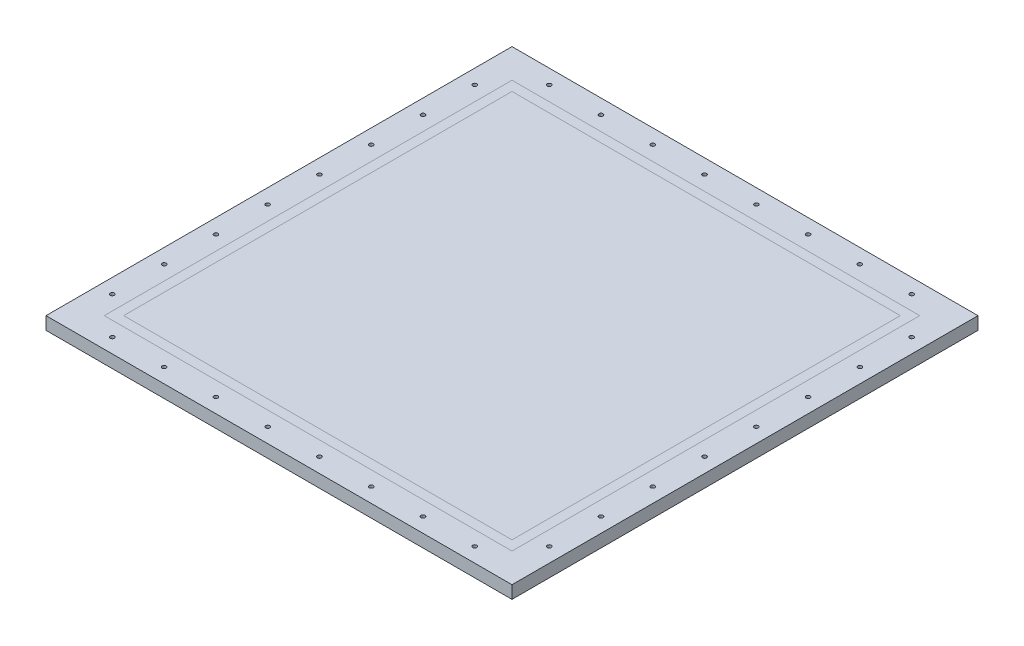
from build123d import *

# Parameters (mm, degrees)
SKETCH1_W                    = 800.1
SKETCH1_H                    = 800.1
BOSS_EXTRUDE1_DEPTH          = 25
SKETCH2_W                    = 914.4
SKETCH2_H                    = 914.4
SKETCH2_W_2                  = 800.1
SKETCH2_H_2                  = 800.1
BOSS_EXTRUDE2_DEPTH          = 25
SKETCH3_W                    = 3.96875
SKETCH3_H                    = 25
LPATTERN1_COUNT              = 4
LPATTERN1_PITCH              = 101.6
LPATTERN1_COL_COUNT          = 5
LPATTERN1_COL_PITCH          = 101.6
CIRPATTERN1_COUNT            = 4
CIRPATTERN1_COPY_1_SKETCH_W  = 3.96875
CIRPATTERN1_COPY_1_SKETCH_H  = 25
CIRPATTERN1_COPY_2_SKETCH_W  = 3.96875
CIRPATTERN1_COPY_2_SKETCH_H  = 25
CIRPATTERN1_COPY_3_SKETCH_W  = 3.96875
CIRPATTERN1_COPY_3_SKETCH_H  = 25
CIRPATTERN1_COPY_4_SKETCH_W  = 3.96875
CIRPATTERN1_COPY_4_SKETCH_H  = 25
CIRPATTERN1_COPY_5_SKETCH_W  = 3.96875
CIRPATTERN1_COPY_5_SKETCH_H  = 25
CIRPATTERN1_COPY_6_SKETCH_W  = 3.96875
CIRPATTERN1_COPY_6_SKETCH_H  = 25
CIRPATTERN1_COPY_7_SKETCH_W  = 3.96875
CIRPATTERN1_COPY_7_SKETCH_H  = 25
CIRPATTERN1_COPY_8_SKETCH_W  = 3.96875
CIRPATTERN1_COPY_8_SKETCH_H  = 25
CIRPATTERN1_COPY_9_SKETCH_W  = 3.96875
CIRPATTERN1_COPY_9_SKETCH_H  = 25
CIRPATTERN1_COPY_10_SKETCH_W = 3.96875
CIRPATTERN1_COPY_10_SKETCH_H = 25
CIRPATTERN1_COPY_11_SKETCH_W = 3.96875
CIRPATTERN1_COPY_11_SKETCH_H = 25
CIRPATTERN1_COPY_12_SKETCH_W = 3.96875
CIRPATTERN1_COPY_12_SKETCH_H = 25
CIRPATTERN1_COPY_13_SKETCH_W = 3.96875
CIRPATTERN1_COPY_13_SKETCH_H = 25
CIRPATTERN1_COPY_14_SKETCH_W = 3.96875
CIRPATTERN1_COPY_14_SKETCH_H = 25
CIRPATTERN1_COPY_15_SKETCH_W = 3.96875
CIRPATTERN1_COPY_15_SKETCH_H = 25
CIRPATTERN1_COPY_16_SKETCH_W = 3.96875
CIRPATTERN1_COPY_16_SKETCH_H = 25
CIRPATTERN1_COPY_17_SKETCH_W = 3.96875
CIRPATTERN1_COPY_17_SKETCH_H = 25
CIRPATTERN1_COPY_18_SKETCH_W = 3.96875
CIRPATTERN1_COPY_18_SKETCH_H = 25
CIRPATTERN1_COPY_19_SKETCH_W = 3.96875
CIRPATTERN1_COPY_19_SKETCH_H = 25
CIRPATTERN1_COPY_20_SKETCH_W = 3.96875
CIRPATTERN1_COPY_20_SKETCH_H = 25
CIRPATTERN1_COPY_21_SKETCH_W = 3.96875
CIRPATTERN1_COPY_21_SKETCH_H = 25


with BuildPart() as part:
    # Sketch1 → Boss-Extrude1 (new body)
    with BuildSketch(Plane(origin=(0, 0, 0), x_dir=(1, 0, 0), z_dir=(0, 1, 0))):
        Rectangle(SKETCH1_W, SKETCH1_H)
    extrude(amount=-BOSS_EXTRUDE1_DEPTH)


with BuildPart() as body_2:
    # Sketch2 → Boss-Extrude2 (new body, through all)
    with BuildSketch(Plane(origin=(0, 0, 0), x_dir=(1, 0, 0), z_dir=(0, 1, 0))):
        Rectangle(SKETCH2_W, SKETCH2_H)
        Rectangle(SKETCH2_W_2, SKETCH2_H_2, mode=Mode.SUBTRACT)
    extrude(amount=-BOSS_EXTRUDE2_DEPTH)

    # Sketch3 → 3_8-16 Tapped Hole1 (revolve, cut)
    with BuildSketch(Plane(origin=(-428.625, 0, 50.8), x_dir=(0, 0, 1), z_dir=(1, 0, 0))):
        with Locations((1.984375, 12.5)):
            Rectangle(SKETCH3_W, SKETCH3_H)
    f_3_8_16_tapped_hole1 = revolve(axis=Axis((-428.625, 6.35, 50.8), (0, -1, 0)), mode=Mode.SUBTRACT)

    # LPattern1: 3_8-16 Tapped Hole1 ×4
    with Locations(*[(0, 0, i * LPATTERN1_PITCH) for i in range(1, LPATTERN1_COUNT)]):
        add(f_3_8_16_tapped_hole1, mode=Mode.SUBTRACT)

    # LPattern1 col: 3_8-16 Tapped Hole1 ×5
    with Locations(*[(0, 0, -i * LPATTERN1_COL_PITCH) for i in range(1, LPATTERN1_COL_COUNT)]):
        add(f_3_8_16_tapped_hole1, mode=Mode.SUBTRACT)

    # CirPattern1: 3_8-16 Tapped Hole1 ×4 about axis
    cirpattern1_axis = Axis((0, 0, 0), (0, 1, 0))
    for i in range(1, CIRPATTERN1_COUNT):
        add(f_3_8_16_tapped_hole1.rotate(cirpattern1_axis, i * 360 / CIRPATTERN1_COUNT), mode=Mode.SUBTRACT)

    # CirPattern1 copy 1 sketch → CirPattern1 copy 1 (revolve, cut)
    with BuildSketch(Plane(origin=(152.4, 0, 428.625), x_dir=(1, 0, 0), z_dir=(0, 0, -1))):
        with Locations((1.984375, 12.5)):
            Rectangle(CIRPATTERN1_COPY_1_SKETCH_W, CIRPATTERN1_COPY_1_SKETCH_H)
    revolve(axis=Axis((152.4, 6.35, 428.625), (0, -1, 0)), mode=Mode.SUBTRACT)

    # CirPattern1 copy 2 sketch → CirPattern1 copy 2 (revolve, cut)
    with BuildSketch(Plane(origin=(428.625, 0, -152.4), x_dir=(0, 0, -1), z_dir=(-1, 0, 0))):
        with Locations((1.984375, 12.5)):
            Rectangle(CIRPATTERN1_COPY_2_SKETCH_W, CIRPATTERN1_COPY_2_SKETCH_H)
    revolve(axis=Axis((428.625, 6.35, -152.4), (0, -1, 0)), mode=Mode.SUBTRACT)

    # CirPattern1 copy 3 sketch → CirPattern1 copy 3 (revolve, cut)
    with BuildSketch(Plane(origin=(-152.4, 0, -428.625), x_dir=(-1, 0, 0), z_dir=(0, 0, 1))):
        with Locations((1.984375, 12.5)):
            Rectangle(CIRPATTERN1_COPY_3_SKETCH_W, CIRPATTERN1_COPY_3_SKETCH_H)
    revolve(axis=Axis((-152.4, 6.35, -428.625), (0, -1, 0)), mode=Mode.SUBTRACT)

    # CirPattern1 copy 4 sketch → CirPattern1 copy 4 (revolve, cut)
    with BuildSketch(Plane(origin=(254, 0, 428.625), x_dir=(1, 0, 0), z_dir=(0, 0, -1))):
        with Locations((1.984375, 12.5)):
            Rectangle(CIRPATTERN1_COPY_4_SKETCH_W, CIRPATTERN1_COPY_4_SKETCH_H)
    revolve(axis=Axis((254, 6.35, 428.625), (0, -1, 0)), mode=Mode.SUBTRACT)

    # CirPattern1 copy 5 sketch → CirPattern1 copy 5 (revolve, cut)
    with BuildSketch(Plane(origin=(428.625, 0, -254), x_dir=(0, 0, -1), z_dir=(-1, 0, 0))):
        with Locations((1.984375, 12.5)):
            Rectangle(CIRPATTERN1_COPY_5_SKETCH_W, CIRPATTERN1_COPY_5_SKETCH_H)
    revolve(axis=Axis((428.625, 6.35, -254), (0, -1, 0)), mode=Mode.SUBTRACT)

    # CirPattern1 copy 6 sketch → CirPattern1 copy 6 (revolve, cut)
    with BuildSketch(Plane(origin=(-254, 0, -428.625), x_dir=(-1, 0, 0), z_dir=(0, 0, 1))):
        with Locations((1.984375, 12.5)):
            Rectangle(CIRPATTERN1_COPY_6_SKETCH_W, CIRPATTERN1_COPY_6_SKETCH_H)
    revolve(axis=Axis((-254, 6.35, -428.625), (0, -1, 0)), mode=Mode.SUBTRACT)

    # CirPattern1 copy 7 sketch → CirPattern1 copy 7 (revolve, cut)
    with BuildSketch(Plane(origin=(355.6, 0, 428.625), x_dir=(1, 0, 0), z_dir=(0, 0, -1))):
        with Locations((1.984375, 12.5)):
            Rectangle(CIRPATTERN1_COPY_7_SKETCH_W, CIRPATTERN1_COPY_7_SKETCH_H)
    revolve(axis=Axis((355.6, 6.35, 428.625), (0, -1, 0)), mode=Mode.SUBTRACT)

    # CirPattern1 copy 8 sketch → CirPattern1 copy 8 (revolve, cut)
    with BuildSketch(Plane(origin=(428.625, 0, -355.6), x_dir=(0, 0, -1), z_dir=(-1, 0, 0))):
        with Locations((1.984375, 12.5)):
            Rectangle(CIRPATTERN1_COPY_8_SKETCH_W, CIRPATTERN1_COPY_8_SKETCH_H)
    revolve(axis=Axis((428.625, 6.35, -355.6), (0, -1, 0)), mode=Mode.SUBTRACT)

    # CirPattern1 copy 9 sketch → CirPattern1 copy 9 (revolve, cut)
    with BuildSketch(Plane(origin=(-355.6, 0, -428.625), x_dir=(-1, 0, 0), z_dir=(0, 0, 1))):
        with Locations((1.984375, 12.5)):
            Rectangle(CIRPATTERN1_COPY_9_SKETCH_W, CIRPATTERN1_COPY_9_SKETCH_H)
    revolve(axis=Axis((-355.6, 6.35, -428.625), (0, -1, 0)), mode=Mode.SUBTRACT)

    # CirPattern1 copy 10 sketch → CirPattern1 copy 10 (revolve, cut)
    with BuildSketch(Plane(origin=(-50.8, 0, 428.625), x_dir=(1, 0, 0), z_dir=(0, 0, -1))):
        with Locations((1.984375, 12.5)):
            Rectangle(CIRPATTERN1_COPY_10_SKETCH_W, CIRPATTERN1_COPY_10_SKETCH_H)
    revolve(axis=Axis((-50.8, 6.35, 428.625), (0, -1, 0)), mode=Mode.SUBTRACT)

    # CirPattern1 copy 11 sketch → CirPattern1 copy 11 (revolve, cut)
    with BuildSketch(Plane(origin=(428.625, 0, 50.8), x_dir=(0, 0, -1), z_dir=(-1, 0, 0))):
        with Locations((1.984375, 12.5)):
            Rectangle(CIRPATTERN1_COPY_11_SKETCH_W, CIRPATTERN1_COPY_11_SKETCH_H)
    revolve(axis=Axis((428.625, 6.35, 50.8), (0, -1, 0)), mode=Mode.SUBTRACT)

    # CirPattern1 copy 12 sketch → CirPattern1 copy 12 (revolve, cut)
    with BuildSketch(Plane(origin=(50.8, 0, -428.625), x_dir=(-1, 0, 0), z_dir=(0, 0, 1))):
        with Locations((1.984375, 12.5)):
            Rectangle(CIRPATTERN1_COPY_12_SKETCH_W, CIRPATTERN1_COPY_12_SKETCH_H)
    revolve(axis=Axis((50.8, 6.35, -428.625), (0, -1, 0)), mode=Mode.SUBTRACT)

    # CirPattern1 copy 13 sketch → CirPattern1 copy 13 (revolve, cut)
    with BuildSketch(Plane(origin=(-152.4, 0, 428.625), x_dir=(1, 0, 0), z_dir=(0, 0, -1))):
        with Locations((1.984375, 12.5)):
            Rectangle(CIRPATTERN1_COPY_13_SKETCH_W, CIRPATTERN1_COPY_13_SKETCH_H)
    revolve(axis=Axis((-152.4, 6.35, 428.625), (0, -1, 0)), mode=Mode.SUBTRACT)

    # CirPattern1 copy 14 sketch → CirPattern1 copy 14 (revolve, cut)
    with BuildSketch(Plane(origin=(428.625, 0, 152.4), x_dir=(0, 0, -1), z_dir=(-1, 0, 0))):
        with Locations((1.984375, 12.5)):
            Rectangle(CIRPATTERN1_COPY_14_SKETCH_W, CIRPATTERN1_COPY_14_SKETCH_H)
    revolve(axis=Axis((428.625, 6.35, 152.4), (0, -1, 0)), mode=Mode.SUBTRACT)

    # CirPattern1 copy 15 sketch → CirPattern1 copy 15 (revolve, cut)
    with BuildSketch(Plane(origin=(152.4, 0, -428.625), x_dir=(-1, 0, 0), z_dir=(0, 0, 1))):
        with Locations((1.984375, 12.5)):
            Rectangle(CIRPATTERN1_COPY_15_SKETCH_W, CIRPATTERN1_COPY_15_SKETCH_H)
    revolve(axis=Axis((152.4, 6.35, -428.625), (0, -1, 0)), mode=Mode.SUBTRACT)

    # CirPattern1 copy 16 sketch → CirPattern1 copy 16 (revolve, cut)
    with BuildSketch(Plane(origin=(-254, 0, 428.625), x_dir=(1, 0, 0), z_dir=(0, 0, -1))):
        with Locations((1.984375, 12.5)):
            Rectangle(CIRPATTERN1_COPY_16_SKETCH_W, CIRPATTERN1_COPY_16_SKETCH_H)
    revolve(axis=Axis((-254, 6.35, 428.625), (0, -1, 0)), mode=Mode.SUBTRACT)

    # CirPattern1 copy 17 sketch → CirPattern1 copy 17 (revolve, cut)
    with BuildSketch(Plane(origin=(428.625, 0, 254), x_dir=(0, 0, -1), z_dir=(-1, 0, 0))):
        with Locations((1.984375, 12.5)):
            Rectangle(CIRPATTERN1_COPY_17_SKETCH_W, CIRPATTERN1_COPY_17_SKETCH_H)
    revolve(axis=Axis((428.625, 6.35, 254), (0, -1, 0)), mode=Mode.SUBTRACT)

    # CirPattern1 copy 18 sketch → CirPattern1 copy 18 (revolve, cut)
    with BuildSketch(Plane(origin=(254, 0, -428.625), x_dir=(-1, 0, 0), z_dir=(0, 0, 1))):
        with Locations((1.984375, 12.5)):
            Rectangle(CIRPATTERN1_COPY_18_SKETCH_W, CIRPATTERN1_COPY_18_SKETCH_H)
    revolve(axis=Axis((254, 6.35, -428.625), (0, -1, 0)), mode=Mode.SUBTRACT)

    # CirPattern1 copy 19 sketch → CirPattern1 copy 19 (revolve, cut)
    with BuildSketch(Plane(origin=(-355.6, 0, 428.625), x_dir=(1, 0, 0), z_dir=(0, 0, -1))):
        with Locations((1.984375, 12.5)):
            Rectangle(CIRPATTERN1_COPY_19_SKETCH_W, CIRPATTERN1_COPY_19_SKETCH_H)
    revolve(axis=Axis((-355.6, 6.35, 428.625), (0, -1, 0)), mode=Mode.SUBTRACT)

    # CirPattern1 copy 20 sketch → CirPattern1 copy 20 (revolve, cut)
    with BuildSketch(Plane(origin=(428.625, 0, 355.6), x_dir=(0, 0, -1), z_dir=(-1, 0, 0))):
        with Locations((1.984375, 12.5)):
            Rectangle(CIRPATTERN1_COPY_20_SKETCH_W, CIRPATTERN1_COPY_20_SKETCH_H)
    revolve(axis=Axis((428.625, 6.35, 355.6), (0, -1, 0)), mode=Mode.SUBTRACT)

    # CirPattern1 copy 21 sketch → CirPattern1 copy 21 (revolve, cut)
    with BuildSketch(Plane(origin=(355.6, 0, -428.625), x_dir=(-1, 0, 0), z_dir=(0, 0, 1))):
        with Locations((1.984375, 12.5)):
            Rectangle(CIRPATTERN1_COPY_21_SKETCH_W, CIRPATTERN1_COPY_21_SKETCH_H)
    revolve(axis=Axis((355.6, 6.35, -428.625), (0, -1, 0)), mode=Mode.SUBTRACT)


solid = Compound([part.part, body_2.part])
